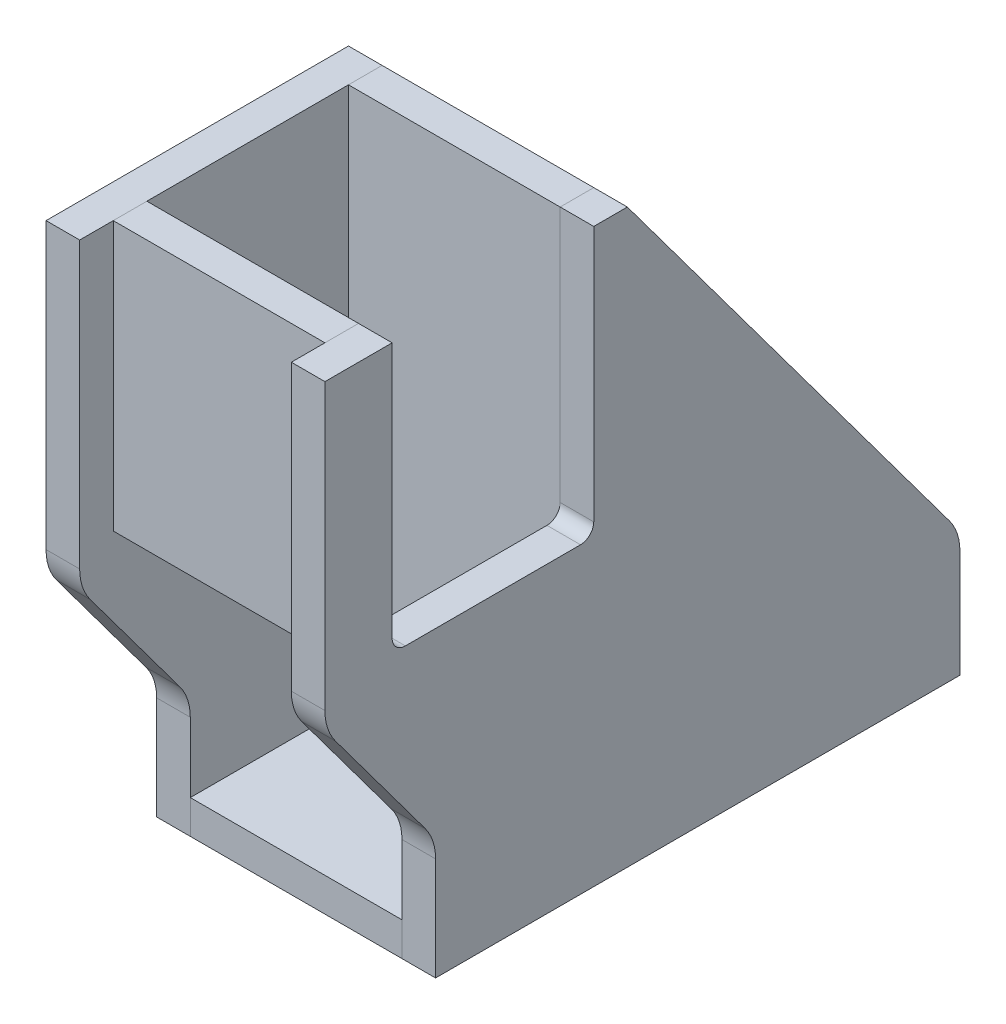
from build123d import *

# Parameters (mm, degrees)
BOSS_EXTRUDE1_START     = 40
SKETCH1_W               = 240
SKETCH1_H               = 216.11
BOSS_EXTRUDE1_DEPTH     = 12.7
CUT_EXTRUDE1_DEPTH      = 1
CUT_EXTRUDE1_DEPTH_BACK = 106.4
BOSS_EXTRUDE2_START     = -12.7
SKETCH3_W               = 198.18830704
SKETCH3_H               = 12.7
BOSS_EXTRUDE2_DEPTH     = 80
BOSS_EXTRUDE3_START     = -12.7
SKETCH4_W               = 12.7
SKETCH4_H               = 203.41
BOSS_EXTRUDE3_DEPTH     = 80
SKETCH5_W               = 12.7
SKETCH5_H               = 101.6
BOSS_EXTRUDE4_DEPTH     = 80
CUT_EXTRUDE2_DEPTH      = 223.7
FILLET1_R               = 20
FILLET2_R               = 20


with BuildPart() as part:
    # Sketch1 → Boss-Extrude1 (new body)
    with BuildSketch(Plane(origin=(0, 0, 0), x_dir=(0, 0, -1), z_dir=(1, 0, 0)).offset(BOSS_EXTRUDE1_START)):
        with Locations((-120, 108.055)):
            Rectangle(SKETCH1_W, SKETCH1_H)
    extrude(amount=BOSS_EXTRUDE1_DEPTH)


with BuildPart() as body_2:
    # Mirror3: mirrored copy
    add(part.part.mirror(Plane(origin=(0, 0, 0), x_dir=(0, 0, 1), z_dir=(1, 0, 0))))


with BuildPart() as cut_extrude1_tool:
    # Sketch2 → Cut-Extrude1 (new body, two sides)
    with BuildSketch(Plane(origin=(52.7, 0, 0), x_dir=(0, 0, -1), z_dir=(1, 0, 0))) as cut_extrude1_sk:
        Polygon((-125.7, 216.11), (0, 47.170775707), (0, 216.11), align=None)
        Polygon((-240, 101.81), (-198.18830704, 45.615608791), (-198.18830704, 0), (-240, 0), align=None)
    extrude(amount=CUT_EXTRUDE1_DEPTH)
    extrude(cut_extrude1_sk.sketch, amount=-CUT_EXTRUDE1_DEPTH_BACK)


with BuildPart() as part_1:
    add(part.part)

    # Cut-Extrude1: cut by cut_extrude1_tool
    add(cut_extrude1_tool.part, mode=Mode.SUBTRACT)

    # Sketch7 → Cut-Extrude2 (cut)
    with BuildSketch(Plane(origin=(0, 0, 0), x_dir=(0, 0, -1), z_dir=(1, 0, 0))):
        with BuildLine():
            Line((-214.6, 216.11), (-138.4, 216.11))
            Line((-138.4, 216.11), (-138.4, 119.405))
            ThreePointArc((-138.4, 119.405), (-139.864466094, 115.869466094), (-143.4, 114.405))
            Line((-143.4, 114.405), (-209.6, 114.405))
            ThreePointArc((-209.6, 114.405), (-213.135533906, 115.869466094), (-214.6, 119.405))
            Line((-214.6, 119.405), (-214.6, 216.11))
        make_face()
    extrude(amount=CUT_EXTRUDE2_DEPTH, mode=Mode.SUBTRACT)

    # Fillet1
    fillet1_edges = [part_1.edges().sort_by_distance(p)[0] for p in [
        (46.35, 47.170775707, 0),
        (46.35, 101.81, 240),
        (46.35, 45.615608791, 198.18830704),
    ]]
    fillet(fillet1_edges, radius=FILLET1_R)


with BuildPart() as body_2_1:
    add(body_2.part)

    # Cut-Extrude1: cut by cut_extrude1_tool
    add(cut_extrude1_tool.part, mode=Mode.SUBTRACT)

    # Fillet2
    fillet2_edges = [body_2_1.edges().sort_by_distance(p)[0] for p in [
        (-46.35, 47.170775707, 0),
        (-46.35, 101.81, 240),
        (-46.35, 45.615608791, 198.18830704),
    ]]
    fillet(fillet2_edges, radius=FILLET2_R)


with BuildPart() as body_3:
    # Sketch3 → Boss-Extrude2 (new body)
    with BuildSketch(Plane(origin=(52.7, 0, 0), x_dir=(0, 0, -1), z_dir=(1, 0, 0)).offset(BOSS_EXTRUDE2_START)):
        with Locations((-99.09415352, 6.35)):
            Rectangle(SKETCH3_W, SKETCH3_H)
    extrude(amount=-BOSS_EXTRUDE2_DEPTH)


with BuildPart() as body_4:
    # Sketch4 → Boss-Extrude3 (new body)
    with BuildSketch(Plane(origin=(52.7, 0, 0), x_dir=(0, 0, -1), z_dir=(1, 0, 0)).offset(BOSS_EXTRUDE3_START)):
        with Locations((-132.05, 114.405)):
            Rectangle(SKETCH4_W, SKETCH4_H)
    extrude(amount=-BOSS_EXTRUDE3_DEPTH)


with BuildPart() as body_5:
    # Sketch5 → Boss-Extrude4 (new body)
    with BuildSketch(Plane(origin=(-40, 0, 0), x_dir=(0, 0, -1), z_dir=(1, 0, 0))):
        with Locations((-220.95, 165.31)):
            Rectangle(SKETCH5_W, SKETCH5_H)
    extrude(amount=BOSS_EXTRUDE4_DEPTH)


solid = Compound([part_1.part, body_2_1.part, body_3.part, body_4.part, body_5.part])
